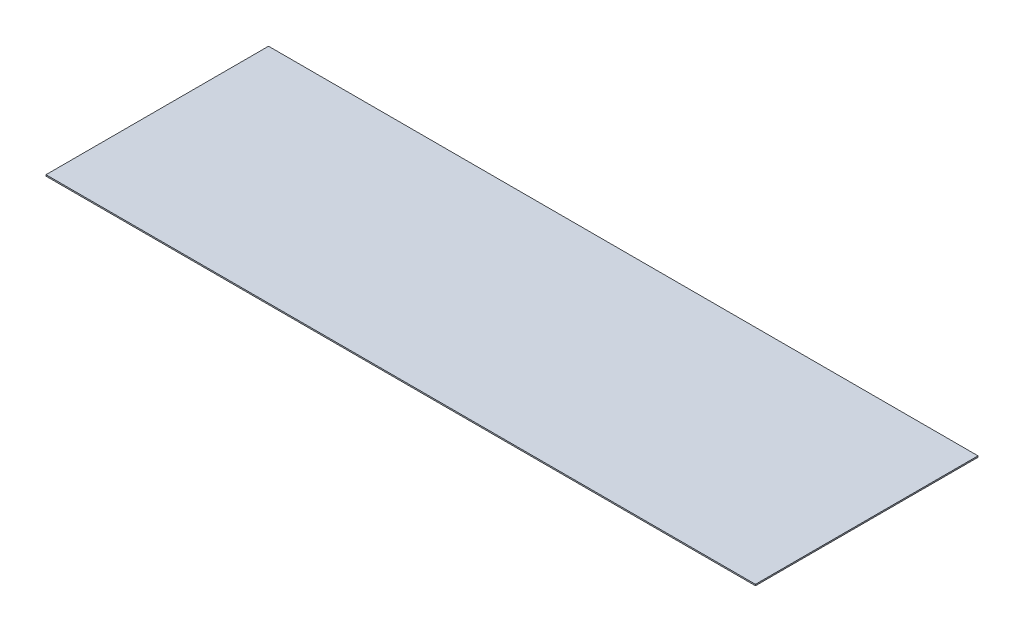
from build123d import *

# Parameters (mm, degrees)
SKETCH1_W           = 542
SKETCH1_H           = 170
BOSS_EXTRUDE1_DEPTH = 1


with BuildPart() as part:
    # Sketch1 → Boss-Extrude1 (new body)
    with BuildSketch(Plane(origin=(0, 0, 0), x_dir=(1, 0, 0), z_dir=(0, 1, 0))):
        Rectangle(SKETCH1_W, SKETCH1_H)
    extrude(amount=BOSS_EXTRUDE1_DEPTH)


solid = part.part
